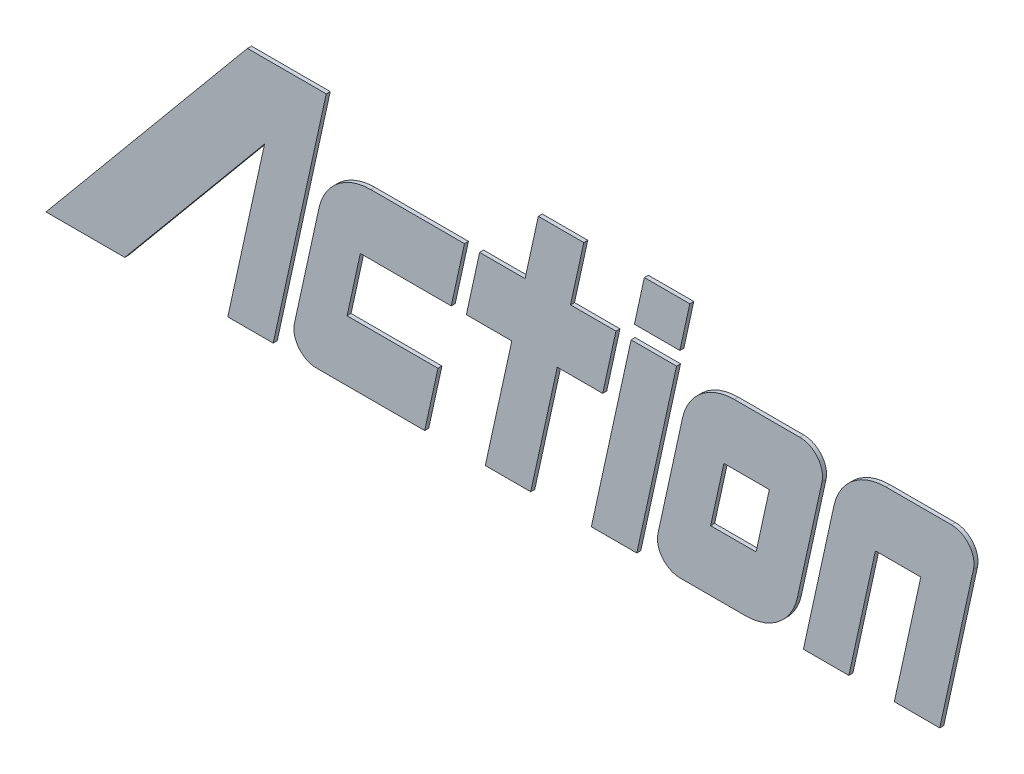
from build123d import *

# Parameters (mm, degrees)
EXTRUDE_1_DEPTH   = 0.1
EXTRUDE_1_2_DEPTH = 0.1
EXTRUDE_1_3_DEPTH = 0.1
EXTRUDE_1_4_DEPTH = 0.1
EXTRUDE_1_5_DEPTH = 0.1
EXTRUDE_1_6_DEPTH = 0.1
EXTRUDE_1_7_DEPTH = 0.1


with BuildPart() as part:
    # Model → 凸台-拉伸1 (new body)
    with BuildSketch(Plane.XY):
        with BuildLine():
            Line((-1190.478526859, 977.862250119), (-1189.862850473, 980.676770742))
            ThreePointArc((-1189.862850473, 980.676770742), (-1189.975335469, 981.15463877), (-1190.418127061, 981.366644271))
            Line((-1190.418127061, 981.366644271), (-1192.054861552, 981.366644271))
            ThreePointArc((-1192.054861552, 981.366644271), (-1192.886464525, 981.073542177), (-1193.350506926, 980.323784221))
            Line((-1193.350506926, 980.323784221), (-1193.966183312, 977.509263598))
            ThreePointArc((-1193.966183312, 977.509263598), (-1193.853698316, 977.03139557), (-1193.410906724, 976.819390069))
            Line((-1193.410906724, 976.819390069), (-1191.774172233, 976.819390069))
            ThreePointArc((-1191.774172233, 976.819390069), (-1190.94256926, 977.112492163), (-1190.478526859, 977.862250119))
        make_face()
        Polygon((-1192.648708977, 978.335141469), (-1192.317138358, 979.85089287), (-1191.180324808, 979.85089287), (-1191.511895427, 978.335141469), align=None, mode=Mode.SUBTRACT)
    extrude(amount=EXTRUDE_1_DEPTH)


with BuildPart() as body_2:
    # Model → Extrude 1 2 (new body)
    with BuildSketch(Plane.XY):
        with BuildLine():
            Line((-1201.743217383, 978.335141469), (-1201.411646764, 979.85089287))
            Line((-1201.411646764, 979.85089287), (-1199.138019662, 979.85089287))
            Line((-1199.138019662, 979.85089287), (-1198.806449043, 981.366644271))
            Line((-1198.806449043, 981.366644271), (-1201.149369958, 981.366644271))
            ThreePointArc((-1201.149369958, 981.366644271), (-1201.980972931, 981.073542177), (-1202.445015332, 980.323784221))
            Line((-1202.445015332, 980.323784221), (-1203.060691718, 977.509263598))
            ThreePointArc((-1203.060691718, 977.509263598), (-1202.948206721, 977.03139557), (-1202.505415129, 976.819390069))
            Line((-1202.505415129, 976.819390069), (-1199.8011609, 976.819390069))
            Line((-1199.8011609, 976.819390069), (-1199.469590281, 978.335141469))
            Line((-1199.469590281, 978.335141469), (-1201.743217383, 978.335141469))
        make_face()
    extrude(amount=EXTRUDE_1_2_DEPTH)


with BuildPart() as body_3:
    # Model → Extrude 1 3 (new body)
    with BuildSketch(Plane.XY):
        Polygon((-1197.290697643, 981.366644271), (-1198.427511193, 981.366644271), (-1198.759081812, 979.85089287), (-1197.622268262, 979.85089287), (-1198.285409499, 976.819390069), (-1197.148595949, 976.819390069), (-1196.485454711, 979.85089287), (-1195.34864116, 979.85089287), (-1195.017070541, 981.366644271), (-1196.153884092, 981.366644271), (-1195.822313473, 982.882395672), (-1196.959127024, 982.882395672), align=None)
    extrude(amount=EXTRUDE_1_3_DEPTH)


with BuildPart() as body_4:
    # Model → Extrude 1 4 (new body)
    with BuildSketch(Plane.XY):
        Polygon((-1193.50131914, 981.366644271), (-1194.638132691, 981.366644271), (-1195.632844548, 976.819390069), (-1194.496030997, 976.819390069), align=None)
    extrude(amount=EXTRUDE_1_4_DEPTH)


with BuildPart() as body_5:
    # Model → Extrude 1 5 (new body)
    with BuildSketch(Plane.XY):
        with BuildLine():
            Line((-1186.628748559, 981.366644271), (-1188.26548305, 981.366644271))
            ThreePointArc((-1188.26548305, 981.366644271), (-1189.097086023, 981.073542177), (-1189.561128424, 980.323784221))
            Line((-1189.561128424, 980.323784221), (-1190.327714645, 976.819390069))
            Line((-1190.327714645, 976.819390069), (-1189.190901094, 976.819390069))
            Line((-1189.190901094, 976.819390069), (-1188.527759856, 979.85089287))
            Line((-1188.527759856, 979.85089287), (-1187.390946306, 979.85089287))
            Line((-1187.390946306, 979.85089287), (-1188.054087543, 976.819390069))
            Line((-1188.054087543, 976.819390069), (-1186.917273993, 976.819390069))
            Line((-1186.917273993, 976.819390069), (-1186.07347197, 980.676770742))
            ThreePointArc((-1186.07347197, 980.676770742), (-1186.185956967, 981.15463877), (-1186.628748559, 981.366644271))
        make_face()
    extrude(amount=EXTRUDE_1_5_DEPTH)


with BuildPart() as body_6:
    # Model → Extrude 1 6 (new body)
    with BuildSketch(Plane.XY):
        Polygon((-1203.590539403, 976.819390069), (-1202.264256927, 982.882395672), (-1204.235224551, 982.882395672), (-1209.274607156, 976.819390069), (-1207.303639532, 976.819390069), (-1203.807128983, 981.026128217), (-1204.727352953, 976.819390069), align=None)
    extrude(amount=EXTRUDE_1_6_DEPTH)


with BuildPart() as body_7:
    # Model → Extrude 1 7 (new body)
    with BuildSketch(Plane.XY):
        Polygon((-1194.306562072, 982.882395672), (-1194.555240036, 981.745582121), (-1193.418426486, 981.745582121), (-1193.169748521, 982.882395672), align=None)
    extrude(amount=EXTRUDE_1_7_DEPTH)


solid = Compound([part.part, body_2.part, body_3.part, body_4.part, body_5.part, body_6.part, body_7.part])
